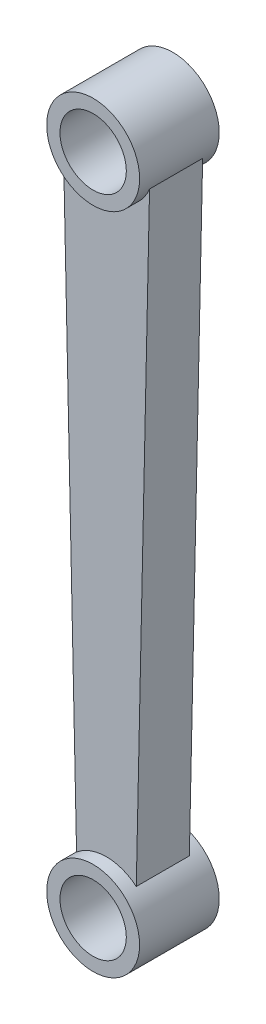
from build123d import *

# Parameters (mm, degrees)
BOSS_EXTRUDE1_DEPTH       = 1.5
BOSS_EXTRUDE1_DEPTH_BACK  = 1.5
SKETCH10_R                = 1.75
SKETCH10_R_2              = 1.25
BOSS_EXTRUDE12_DEPTH      = 1.5
BOSS_EXTRUDE12_DEPTH_BACK = 1.5
SKETCH11_R                = 1.75
SKETCH11_R_2              = 1.25
BOSS_EXTRUDE13_DEPTH      = 1
BOSS_EXTRUDE13_DEPTH_BACK = 1
SKETCH1_R                 = 1.25


with BuildPart() as part:
    # Sketch10 → Boss-Extrude1 (new, two sides: drawn at the far end of the back side and taken through both)
    with BuildSketch(Plane.XY.offset(-BOSS_EXTRUDE1_DEPTH_BACK)):
        Circle(SKETCH10_R)
        Circle(SKETCH10_R_2, mode=Mode.SUBTRACT)
    extrude(amount=BOSS_EXTRUDE1_DEPTH + BOSS_EXTRUDE1_DEPTH_BACK)



with BuildPart() as body_2:
    # Sketch11 → Boss-Extrude12 (new, two sides: drawn at the far end of the back side and taken through both)
    with BuildSketch(Plane.XY.offset(-BOSS_EXTRUDE12_DEPTH_BACK)):
        with Locations((0, -25)):
            Circle(SKETCH11_R)
        with Locations((0, -25)):
            Circle(SKETCH11_R_2, mode=Mode.SUBTRACT)
    extrude(amount=BOSS_EXTRUDE12_DEPTH + BOSS_EXTRUDE12_DEPTH_BACK)


with BuildPart() as part_1:
    add(part.part)

    add(body_2.part)  # Boss-Extrude13 merges body 2
    # Sketch1 → Boss-Extrude13 (add, two sides: drawn at the far end of the back side and taken through both)
    with BuildSketch(Plane.XY.offset(-BOSS_EXTRUDE13_DEPTH_BACK)):
        with BuildLine():
            Line((-1.625, -0.649519053), (-1.125, -23.659524338))
            ThreePointArc((-1.125, -23.659524338), (0, -26.75), (1.125, -23.659524338))
            Line((1.125, -23.659524338), (1.625, -0.649519053))
            ThreePointArc((1.625, -0.649519053), (0, 1.75), (-1.625, -0.649519053))
        make_face()
        Circle(SKETCH1_R, mode=Mode.SUBTRACT)
        with Locations((0, -25)):
            Circle(SKETCH1_R, mode=Mode.SUBTRACT)
    extrude(amount=BOSS_EXTRUDE13_DEPTH + BOSS_EXTRUDE13_DEPTH_BACK)


solid = part_1.part
